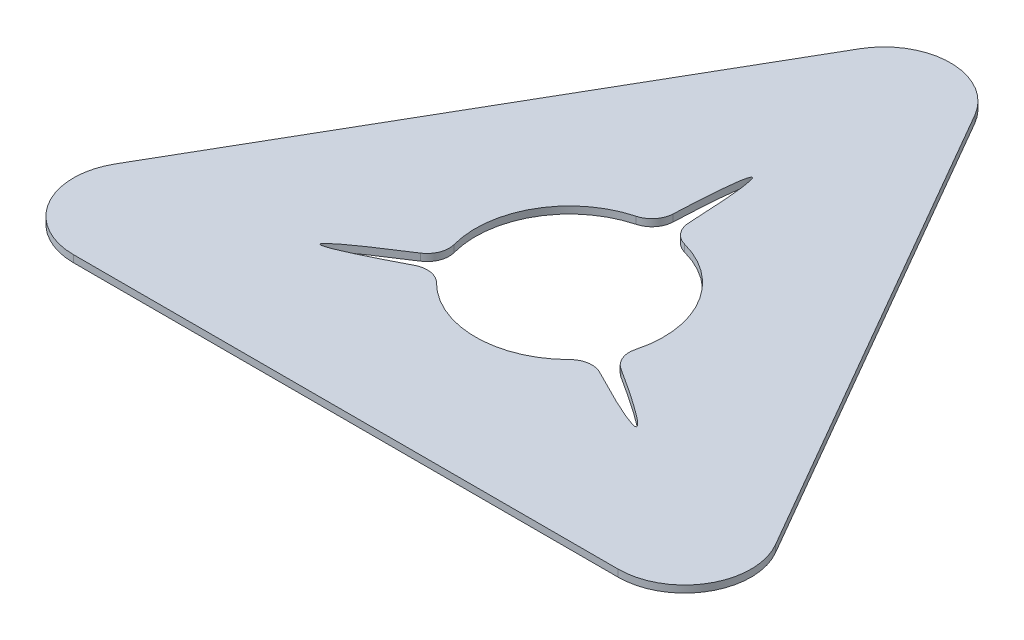
from build123d import *

# Parameters (mm, degrees)
BOSS_EXTRUDE1_DEPTH = 6.35
SKETCH2_R           = 85
CUT_EXTRUDE1_DEPTH  = 6.35
FILLET1_R           = 60
CUT_EXTRUDE2_DEPTH  = 6.35
FILLET2_R           = 20


with BuildPart() as part:
    # Sketch1 → Boss-Extrude1 (new body)
    with BuildSketch(Plane(origin=(0, 0, 0), x_dir=(1, 0, 0), z_dir=(0, 1, 0))):
        Polygon((0, 0), (-350, -606.217782649), (350, -606.217782649), align=None)
    extrude(amount=BOSS_EXTRUDE1_DEPTH)

    # Sketch2 → Cut-Extrude1 (cut)
    with BuildSketch(Plane(origin=(0, 6.35, 0), x_dir=(1, 0, 0), z_dir=(0, 1, 0))):
        with Locations(Location((0, -404.145188433, 0), (0, 0, 270))):
            Circle(SKETCH2_R)
    extrude(amount=-CUT_EXTRUDE1_DEPTH, mode=Mode.SUBTRACT)

    # Fillet1
    fillet1_edges = [part.edges().sort_by_distance(p)[0] for p in [
        (350, 3.175, 606.217782649),
        (-350, 3.175, 606.217782649),
        (0, 3.175, 0),
    ]]
    fillet(fillet1_edges, radius=FILLET1_R)

    # Sketch3 → Cut-Extrude2 (cut)
    with BuildSketch(Plane(origin=(0, 6.35, 0), x_dir=(1, 0, 0), z_dir=(0, 1, 0))):
        with BuildLine():
            Line((30.480762114, -411.350959799), (21.480762114, -426.939417067))
            add(Edge.make_bspline(
                [(30.480762114, -411.350959799), (545.596004384, -719.145188433), (21.480762114, -426.939417067)],
                knots=[0, 0, 0, 1, 1, 1], degree=2, weights=[1, 0.290322581, 1]))
        make_face()
        with BuildLine():
            Line((-9, -374.145188433), (9, -374.145188433))
            add(Edge.make_bspline(
                [(-9, -374.145188433), (0, 225.854811567), (9, -374.145188433)],
                knots=[0, 0, 0, 1, 1, 1], degree=2, weights=[1, 0.290322581, 1]))
        make_face()
        with BuildLine():
            Line((-21.480762114, -426.939417067), (-30.480762114, -411.350959799))
            add(Edge.make_bspline(
                [(-21.480762114, -426.939417067), (-545.596004384, -719.145188433), (-30.480762114, -411.350959799)],
                knots=[0, 0, 0, 1, 1, 1], degree=2, weights=[1, 0.290322581, 1]))
        make_face()
    extrude(amount=-CUT_EXTRUDE2_DEPTH, mode=Mode.SUBTRACT)

    # Fillet2
    fillet2_edges = [part.edges().sort_by_distance(p)[0] for p in [
        (-7.677401055, 3.175, 319.492618991),
        (7.677401055, 3.175, 319.492618991),
        (77.149976159, 3.175, 439.822648805),
        (69.472575104, 3.175, 453.120297502),
        (-69.472575104, 3.175, 453.120297502),
        (-77.149976159, 3.175, 439.822648805),
    ]]
    fillet(fillet2_edges, radius=FILLET2_R)


solid = part.part
